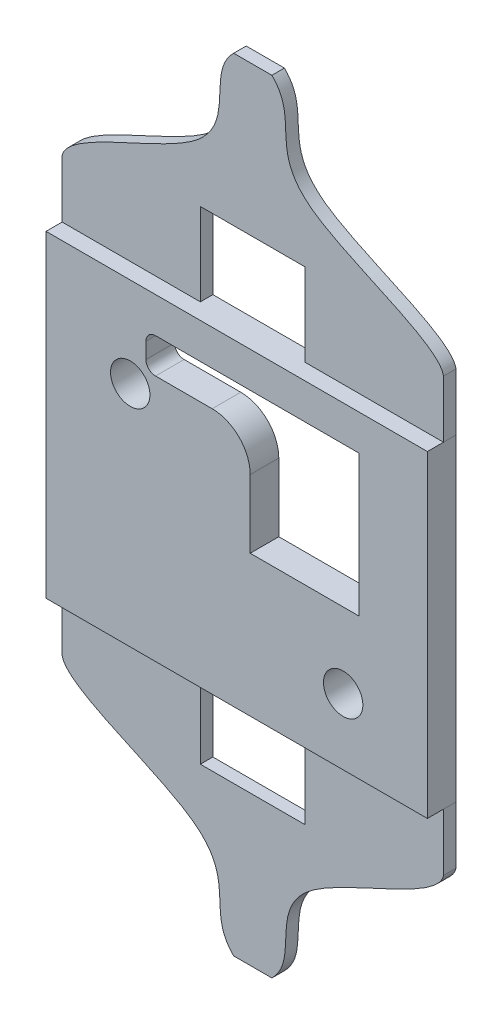
from build123d import *

# Parameters (mm, degrees)
SKETCH2_W             = 30.48
SKETCH2_H             = 25.4
BOSS_EXTRUDE1_DEPTH   = 2.286
CUT_EXTRUDE2_REACH    = 4.286
SKETCH3_R             = 1.5748
BOSS_EXTRUDE5_DEPTH   = 1
BOSS_EXTRUDE5_2_DEPTH = 1
CUT_EXTRUDE3_DEPTH    = 1
FILLET4_R             = 3.04
FILLET5_R             = 0.762


with BuildPart() as part:
    # Sketch2 → Boss-Extrude1 (new body)
    with BuildSketch(Plane.XY):
        Rectangle(SKETCH2_W, SKETCH2_H)
    extrude(amount=BOSS_EXTRUDE1_DEPTH)

    # Sketch3 → Cut-Extrude2 (cut, up to next)
    with BuildSketch(Plane(origin=(0, 0, 0), x_dir=(-1, 0, 0), z_dir=(0, 0, -1)), mode=Mode.PRIVATE) as cut_extrude2_sk1:
        Polygon((-9.7663, -1.4224), (-1.0795, -1.4224), (-1.0795, 7.0612), (7.2517, 7.0612), (7.2517, 9.8552), (-9.7663, 9.8552), align=None)
    cut_extrude2_tool1 = extrude(cut_extrude2_sk1.sketch, amount=-CUT_EXTRUDE2_REACH, mode=Mode.PRIVATE) & part.part
    add(cut_extrude2_tool1.solids().sort_by_distance((3.789271, 5.030776, 0))[0], mode=Mode.SUBTRACT)
    # Sketch3 → Cut-Extrude2 (cut, up to next)
    with BuildSketch(Plane(origin=(0, 0, 0), x_dir=(-1, 0, 0), z_dir=(0, 0, -1)), mode=Mode.PRIVATE) as cut_extrude2_sk2:
        with Locations((8.509, 5.5245)):
            Circle(SKETCH3_R)
    cut_extrude2_tool2 = extrude(cut_extrude2_sk2.sketch, amount=-CUT_EXTRUDE2_REACH, mode=Mode.PRIVATE) & part.part
    add(cut_extrude2_tool2.solids().sort_by_distance((-8.509, 5.5245, 0))[0], mode=Mode.SUBTRACT)
    # Sketch3 → Cut-Extrude2 (cut, up to next)
    with BuildSketch(Plane(origin=(0, 0, 0), x_dir=(-1, 0, 0), z_dir=(0, 0, -1)), mode=Mode.PRIVATE) as cut_extrude2_sk3:
        with Locations((-8.509, -7.4295)):
            Circle(SKETCH3_R)
    cut_extrude2_tool3 = extrude(cut_extrude2_sk3.sketch, amount=-CUT_EXTRUDE2_REACH, mode=Mode.PRIVATE) & part.part
    add(cut_extrude2_tool3.solids().sort_by_distance((8.509, -7.4295, 0))[0], mode=Mode.SUBTRACT)

    # Fillet4
    fillet4_edges = [part.edges().sort_by_distance(p)[0] for p in [
        (1.0795, 7.0612, 1.143),
    ]]
    fillet(fillet4_edges, radius=FILLET4_R)

    # Fillet5
    fillet5_edges = [part.edges().sort_by_distance(p)[0] for p in [
        (-7.2517, 9.8552, 1.143),
        (-7.2517, 7.0612, 1.143),
    ]]
    fillet(fillet5_edges, radius=FILLET5_R)


with BuildPart() as body_2:
    # Sketch5 → Boss-Extrude5 (new body)
    with BuildSketch(Plane(origin=(0, 0, 0), x_dir=(-1, 0, 0), z_dir=(0, 0, -1))):
        Polygon((-15.24, 12.7), (-4.191, 12.7), (-4.191, 19.304), (4.191, 19.304), (4.191, 12.7), (15.24, 12.7), (15.24, 31.242), (-15.24, 31.242), align=None)
    extrude(amount=-BOSS_EXTRUDE5_DEPTH)


with BuildPart() as body_3:
    # Sketch5 → Boss-Extrude5 2 (new body)
    with BuildSketch(Plane(origin=(0, 0, 0), x_dir=(-1, 0, 0), z_dir=(0, 0, -1))):
        Polygon((15.24, -12.7), (4.191, -12.7), (4.191, -19.304), (-4.191, -19.304), (-4.191, -12.7), (-15.24, -12.7), (-15.24, -31.242), (15.24, -31.242), align=None)
    extrude(amount=-BOSS_EXTRUDE5_2_DEPTH)


with BuildPart() as cut_extrude3_tool:
    # Sketch6 → Cut-Extrude3 (new body)
    with BuildSketch(Plane(origin=(0, 0, 0), x_dir=(-1, 0, 0), z_dir=(0, 0, -1))):
        with BuildLine():
            Line((15.24, -17.280759688), (15.24, -31.242))
            Line((15.24, -31.242), (1.526938678, -31.242))
            add(Edge.make_bspline(
                [(15.24, -17.280759688), (14.890369571, -19.309691675), (-1.001421423, -23.881680442), (3.798810701, -29.015705658), (1.526938678, -31.242)],
                knots=[0, 0, 0, 0, 0.458669995, 1, 1, 1, 1], degree=3))
        make_face()
        with BuildLine():
            Line((-15.24, -31.242), (-1.526938678, -31.242))
            add(Edge.make_bspline(
                [(-15.24, -17.280759688), (-14.890369571, -19.309691675), (1.001421423, -23.881680442), (-3.798810701, -29.015705658), (-1.526938678, -31.242)],
                knots=[0, 0, 0, 0, 0.458669995, 1, 1, 1, 1], degree=3))
            Line((-15.24, -17.280759688), (-15.24, -31.242))
        make_face()
        with BuildLine():
            Line((-15.24, 17.280759688), (-15.24, 31.242))
            Line((-15.24, 31.242), (-1.526938678, 31.242))
            add(Edge.make_bspline(
                [(-15.24, 17.280759688), (-14.890369571, 19.309691675), (1.001421423, 23.881680442), (-3.798810701, 29.015705658), (-1.526938678, 31.242)],
                knots=[0, 0, 0, 0, 0.458669995, 1, 1, 1, 1], degree=3))
        make_face()
        with BuildLine():
            Line((15.24, 31.242), (1.526938678, 31.242))
            add(Edge.make_bspline(
                [(15.24, 17.280759688), (14.890369571, 19.309691675), (-1.001421423, 23.881680442), (3.798810701, 29.015705658), (1.526938678, 31.242)],
                knots=[0, 0, 0, 0, 0.458669995, 1, 1, 1, 1], degree=3))
            Line((15.24, 17.280759688), (15.24, 31.242))
        make_face()
    extrude(amount=-CUT_EXTRUDE3_DEPTH)


with BuildPart() as body_2_1:
    add(body_2.part)

    # Cut-Extrude3: cut by cut_extrude3_tool
    add(cut_extrude3_tool.part, mode=Mode.SUBTRACT)


with BuildPart() as body_3_1:
    add(body_3.part)

    # Cut-Extrude3: cut by cut_extrude3_tool
    add(cut_extrude3_tool.part, mode=Mode.SUBTRACT)


solid = Compound([part.part, body_2_1.part, body_3_1.part])
